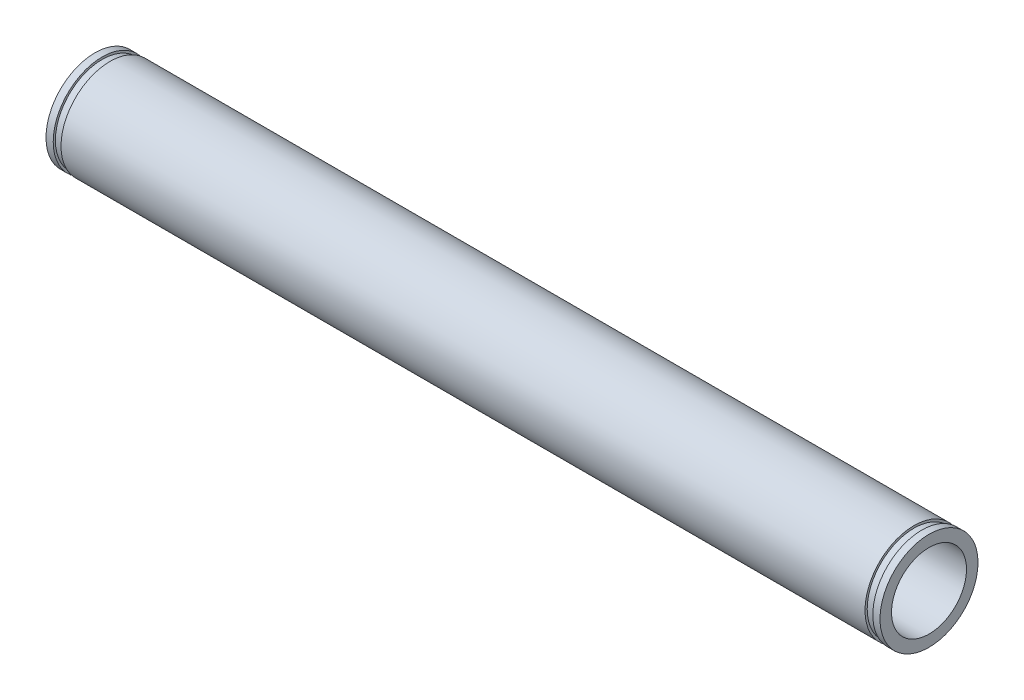
from build123d import *

# Parameters (mm, degrees)
SKETCH1_R           = 6.223
SKETCH1_R_2         = 4.7625
BOSS_EXTRUDE1_DEPTH = 52.959
SKETCH2_R           = 6.35
SKETCH2_R_2         = 5.9436
CUT_EXTRUDE1_DEPTH  = 0.9906


with BuildPart() as part:
    # Sketch1 → Boss-Extrude1 (new body, symmetric)
    with BuildSketch(Plane(origin=(0, 0, 0), x_dir=(0, 0, -1), z_dir=(1, 0, 0))):
        Circle(SKETCH1_R)
        Circle(SKETCH1_R_2, mode=Mode.SUBTRACT)
    extrude(amount=BOSS_EXTRUDE1_DEPTH, both=True)

    # Sketch2 → Cut-Extrude1 (cut)
    with BuildSketch(Plane.ZY.offset(51.054)):
        Circle(SKETCH2_R)
        Circle(SKETCH2_R_2, mode=Mode.SUBTRACT)
    cut_extrude1 = extrude(amount=CUT_EXTRUDE1_DEPTH, mode=Mode.SUBTRACT)

    # Mirror1: Cut-Extrude1 across plane
    add(cut_extrude1.mirror(Plane(origin=(0, 0, 0), x_dir=(0, 0, 1), z_dir=(1, 0, 0))), mode=Mode.SUBTRACT)


solid = part.part
